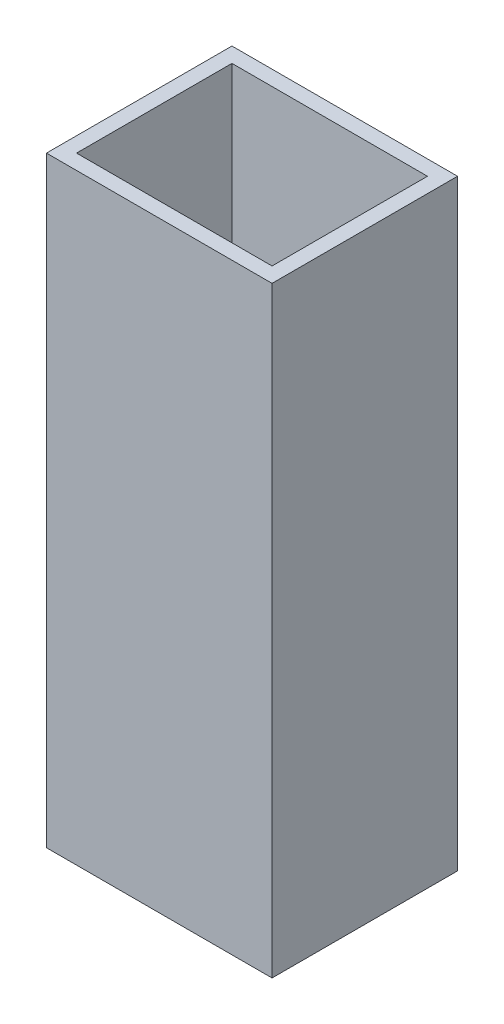
from build123d import *

# Parameters (mm, degrees)
SKETCH2_W           = 45
SKETCH2_H           = 37
BOSS_EXTRUDE1_DEPTH = 3
SKETCH3_W           = 45
SKETCH3_H           = 37
SKETCH3_W_2         = 39
SKETCH3_H_2         = 31
BOSS_EXTRUDE2_DEPTH = 117


with BuildPart() as part:
    # Sketch2 → Boss-Extrude1 (new body)
    with BuildSketch(Plane(origin=(0, 0, 0), x_dir=(1, 0, 0), z_dir=(0, 1, 0))):
        with Locations((22.5, 18.5)):
            Rectangle(SKETCH2_W, SKETCH2_H)
    extrude(amount=BOSS_EXTRUDE1_DEPTH)

    # Sketch3 → Boss-Extrude2 (add)
    with BuildSketch(Plane(origin=(0, 3, 0), x_dir=(1, 0, 0), z_dir=(0, 1, 0))):
        with Locations((22.5, 18.5)):
            Rectangle(SKETCH3_W, SKETCH3_H)
        with Locations((22.5, 18.5)):
            Rectangle(SKETCH3_W_2, SKETCH3_H_2, mode=Mode.SUBTRACT)
    extrude(amount=BOSS_EXTRUDE2_DEPTH)


solid = part.part
